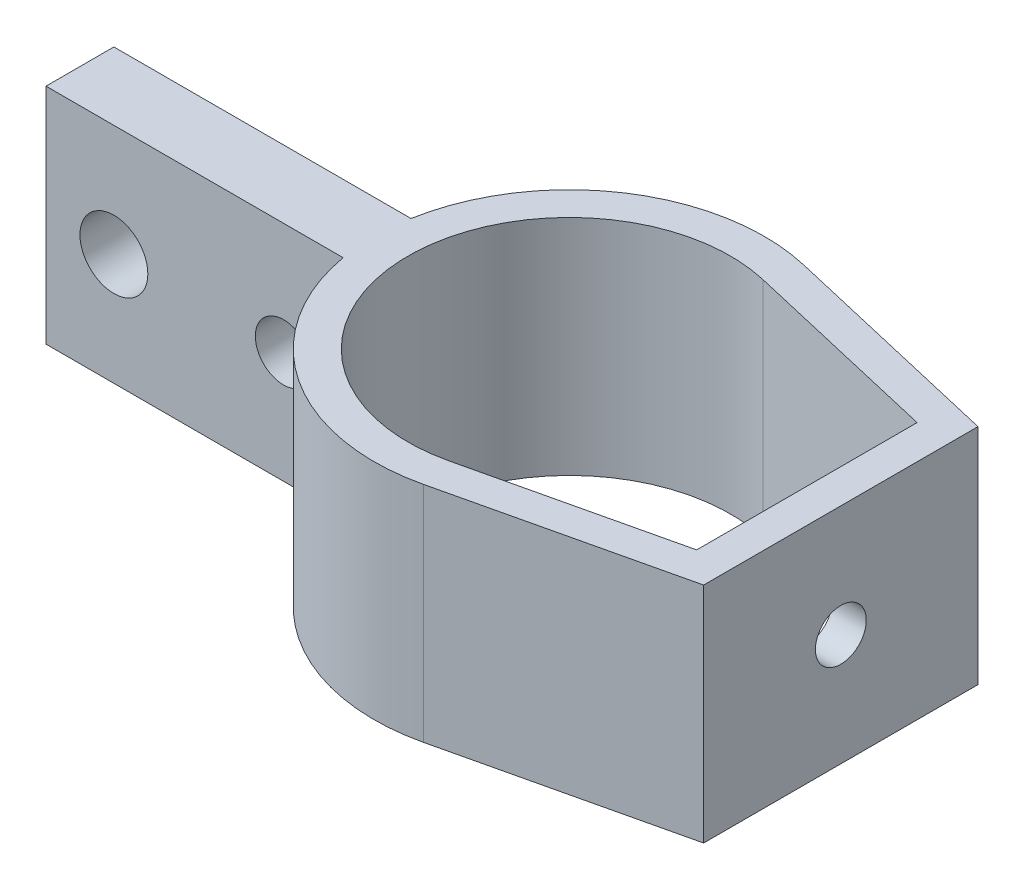
from build123d import *

# Parameters (mm, degrees)
BOSS_EXTRUDE1_DEPTH = 10.033
SKETCH2_R           = 3.048
SKETCH2_R_2         = 2.54
CUT_EXTRUDE1_DEPTH  = 10.033
SKETCH3_R           = 2.286
CUT_EXTRUDE2_DEPTH  = 10.033


with BuildPart() as part:
    # Sketch1 → Boss-Extrude1 (new body, symmetric)
    with BuildSketch(Plane(origin=(0, 0, 0), x_dir=(1, 0, 0), z_dir=(0, 1, 0))):
        with BuildLine():
            Line((24.384, -12.319), (24.384, 12.319))
            Line((24.384, 12.319), (3.973043901, 17.069727536))
            ThreePointArc((3.973043901, 17.069727536), (-9.658201012, 14.624630908), (-17.258921519, 3.048))
            Line((-17.258921519, 3.048), (-43.942, 3.048))
            Line((-43.942, 3.048), (-43.942, -3.048))
            Line((-43.942, -3.048), (-17.258921519, -3.048))
            ThreePointArc((-17.258921519, -3.048), (-9.658201012, -14.624630908), (3.973043901, -17.069727536))
            Line((3.973043901, -17.069727536), (24.384, -12.319))
        make_face()
        with BuildLine():
            Line((21.336, -9.898960775), (21.336, 9.898960775))
            Line((21.336, 9.898960775), (3.282079744, 14.101079269))
            ThreePointArc((3.282079744, 14.101079269), (-14.478, 0), (3.282079744, -14.101079269))
            Line((3.282079744, -14.101079269), (21.336, -9.898960775))
        make_face(mode=Mode.SUBTRACT)
    extrude(amount=BOSS_EXTRUDE1_DEPTH, both=True)

    # Sketch2 → Cut-Extrude1 (cut, symmetric)
    with BuildSketch(Plane.XY.offset(3.048)):
        with Locations((-37.846, 0)):
            Circle(SKETCH2_R)
        with Locations((-22.606, 0)):
            Circle(SKETCH2_R_2)
    extrude(amount=CUT_EXTRUDE1_DEPTH, both=True, mode=Mode.SUBTRACT)

    # Sketch3 → Cut-Extrude2 (cut, symmetric)
    with BuildSketch(Plane(origin=(24.384, 0, 0), x_dir=(0, 0, -1), z_dir=(1, 0, 0))):
        Circle(SKETCH3_R)
    extrude(amount=CUT_EXTRUDE2_DEPTH, both=True, mode=Mode.SUBTRACT)


solid = part.part
